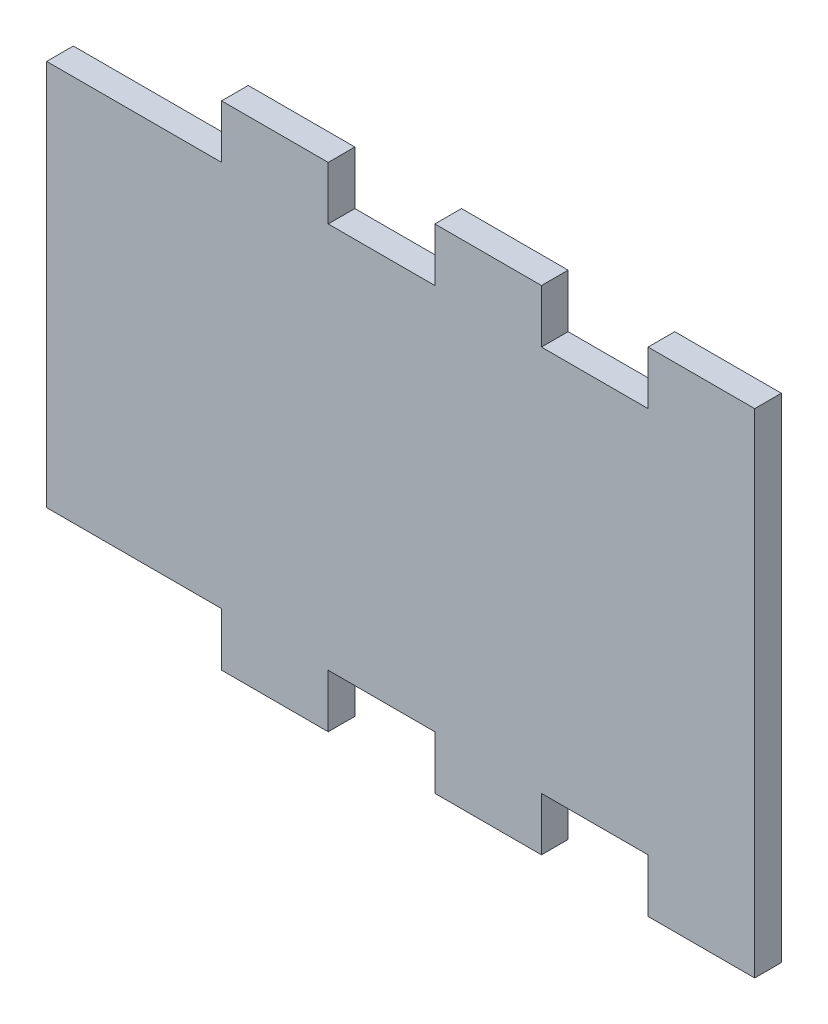
from build123d import *

# Parameters (mm, degrees)
BOSS_EXTRUDE1_DEPTH = 3.175


with BuildPart() as part:
    # Sketch1 → Boss-Extrude1 (new body)
    with BuildSketch(Plane.XY):
        Polygon((-38.1, 46.03496), (-38.1, 52.38496), (-25.4, 52.38496), (-25.4, 46.03496), (-12.7, 46.03496), (-12.7, 52.38496), (0, 52.38496), (0, 46.03496), (0, 0), (0, -6.35), (-12.7, -6.35), (-12.7, 0), (-25.4, 0), (-25.4, -6.35), (-38.1, -6.35), (-38.1, 0), (-50.8, 0), (-50.8, -6.35), (-63.5, -6.35), (-63.5, 0), (-76.2, 0), (-84.33816, 0), (-84.33816, 46.03496), (-76.2, 46.03496), (-63.5, 46.03496), (-63.5, 52.38496), (-50.8, 52.38496), (-50.8, 46.03496), align=None)
    extrude(amount=BOSS_EXTRUDE1_DEPTH)


solid = part.part
